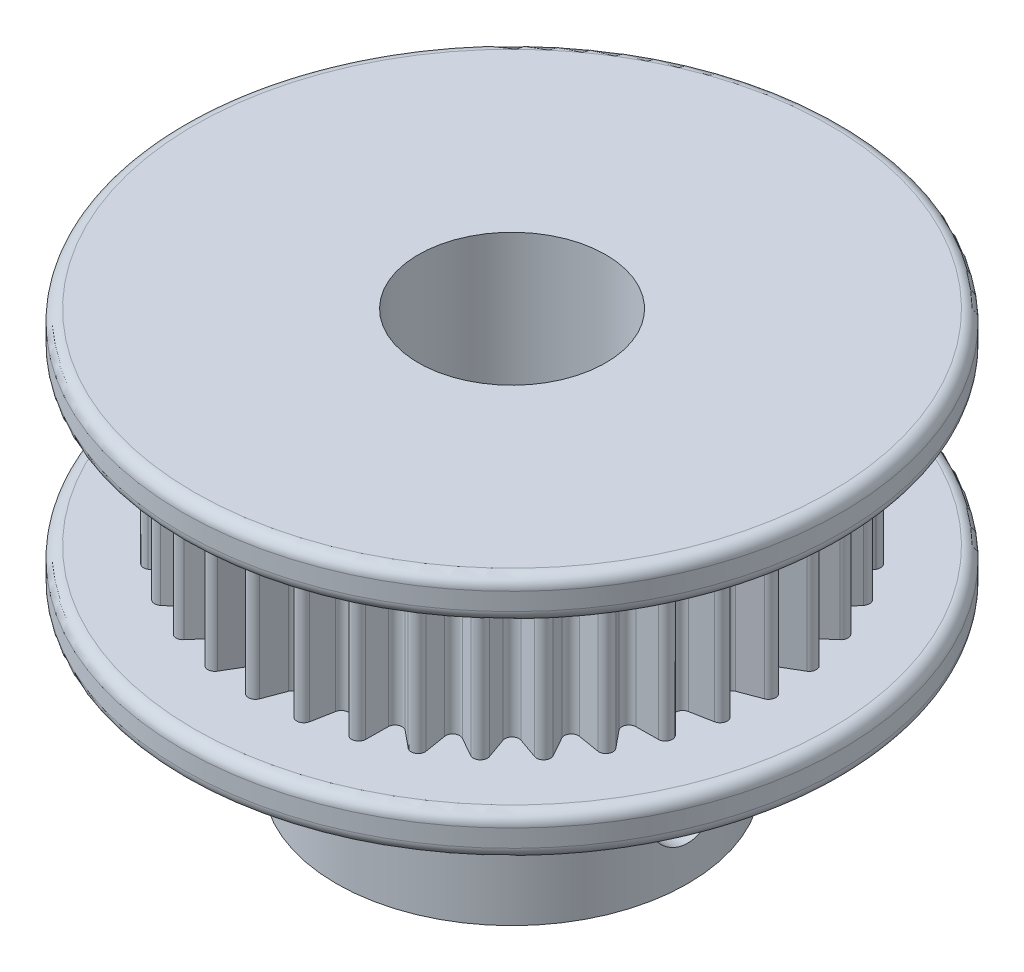
from build123d import *

# Parameters (mm, degrees)
SKETCH1_R           = 7.5
BOSS_EXTRUDE1_DEPTH = 7
SKETCH7_R           = 14.065
BOSS_EXTRUDE5_DEPTH = 1.75
BOSS_EXTRUDE7_DEPTH = 7
SKETCH8_R           = 14.065
BOSS_EXTRUDE6_DEPTH = 1.75
SKETCH4_R           = 4
CUT_EXTRUDE4_DEPTH  = 18.5
SKETCH5_R           = 1.5
CUT_EXTRUDE2_DEPTH  = 15.065
SKETCH6_R           = 1.5
CUT_EXTRUDE3_DEPTH  = 15.065
FILLET1_R           = 0.5


with BuildPart() as part:
    # Sketch1 → Boss-Extrude1 (new body)
    with BuildSketch(Plane(origin=(0, 0, 0), x_dir=(1, 0, 0), z_dir=(0, 1, 0))):
        Circle(SKETCH1_R)
    extrude(amount=BOSS_EXTRUDE1_DEPTH)

    # Sketch7 → Boss-Extrude5 (add)
    with BuildSketch(Plane(origin=(0, 7, 0), x_dir=(1, 0, 0), z_dir=(0, 1, 0))):
        Circle(SKETCH7_R)
    extrude(amount=BOSS_EXTRUDE5_DEPTH)

    # Sketch9 → Boss-Extrude7 (add)
    with BuildSketch(Plane(origin=(0, 8.75, 0), x_dir=(1, 0, 0), z_dir=(0, 1, 0))):
        with BuildLine():
            Line((0.280660726, 11.055969605), (0.617769602, 10.163136024))
            ThreePointArc((0.617769602, 10.163136024), (0.872283604, 9.970247219), (1.156425757, 10.116009717))
            Line((1.156425757, 10.116009717), (1.643452116, 10.936740807))
            ThreePointArc((1.643452116, 10.936740807), (1.776289931, 11.056290401), (1.953541999, 11.079087221))
            ThreePointArc((1.953541999, 11.079087221), (2.112307487, 10.99704144), (2.196245833, 10.83926836))
            Line((2.196245833, 10.83926836), (2.373194343, 9.901460586))
            ThreePointArc((2.373194343, 9.901460586), (2.590346917, 9.667306303), (2.895483704, 9.761513574))
            Line((2.895483704, 9.761513574), (3.517629496, 10.485204675))
            ThreePointArc((3.517629496, 10.485204675), (3.669208776, 10.579870997), (3.847726612, 10.571541984))
            ThreePointArc((3.847726612, 10.571541984), (3.989832996, 10.463173324), (4.045099122, 10.293221432))
            Line((4.045099122, 10.293221432), (4.056510776, 9.338934278))
            ThreePointArc((4.056510776, 9.338934278), (4.229703849, 9.070629176), (4.546563843, 9.11041878))
            Line((4.546563843, 9.11041878), (5.284925484, 9.715080904))
            ThreePointArc((5.284925484, 9.715080904), (5.450640568, 9.781987566), (5.625, 9.742785793))
            ThreePointArc((5.625, 9.742785793), (5.746129448, 9.611386982), (5.771044121, 9.434420178))
            Line((5.771044121, 9.434420178), (5.616572181, 8.492649178))
            ThreePointArc((5.616572181, 8.492649178), (5.74054337, 8.198345572), (6.059498941, 8.182508521))
            Line((6.059498941, 8.182508521), (6.891641686, 8.649769316))
            ThreePointArc((6.891641686, 8.649769316), (7.066457405, 8.686883393), (7.231360609, 8.617999985))
            ThreePointArc((7.231360609, 8.617999985), (7.327832664, 8.46756351), (7.321638864, 8.288958842))
            Line((7.321638864, 8.288958842), (7.005976882, 7.38831923))
            ThreePointArc((7.005976882, 7.38831923), (7.076959386, 7.076959386), (7.38831923, 7.005976882))
            Line((7.38831923, 7.005976882), (8.288958842, 7.321638864))
            ThreePointArc((8.288958842, 7.321638864), (8.46756351, 7.327832664), (8.617999985, 7.231360609))
            ThreePointArc((8.617999985, 7.231360609), (8.686883393, 7.066457405), (8.649769316, 6.891641686))
            Line((8.649769316, 6.891641686), (8.182508521, 6.059498941))
            ThreePointArc((8.182508521, 6.059498941), (8.198345572, 5.74054337), (8.492649178, 5.616572181))
            Line((8.492649178, 5.616572181), (9.434420178, 5.771044121))
            ThreePointArc((9.434420178, 5.771044121), (9.611386982, 5.746129448), (9.742785793, 5.625))
            ThreePointArc((9.742785793, 5.625), (9.781987566, 5.450640568), (9.715080904, 5.284925484))
            Line((9.715080904, 5.284925484), (9.11041878, 4.546563843))
            ThreePointArc((9.11041878, 4.546563843), (9.070629176, 4.229703849), (9.338934278, 4.056510776))
            Line((9.338934278, 4.056510776), (10.293221432, 4.045099122))
            ThreePointArc((10.293221432, 4.045099122), (10.463173324, 3.989832996), (10.571541984, 3.847726612))
            ThreePointArc((10.571541984, 3.847726612), (10.579870997, 3.669208776), (10.485204675, 3.517629496))
            Line((10.485204675, 3.517629496), (9.761513574, 2.895483704))
            ThreePointArc((9.761513574, 2.895483704), (9.667306303, 2.590346917), (9.901460586, 2.373194343))
            Line((9.901460586, 2.373194343), (10.83926836, 2.196245833))
            ThreePointArc((10.83926836, 2.196245833), (10.99704144, 2.112307487), (11.079087221, 1.953541999))
            ThreePointArc((11.079087221, 1.953541999), (11.056290401, 1.776289931), (10.936740807, 1.643452116))
            Line((10.936740807, 1.643452116), (10.116009717, 1.156425757))
            ThreePointArc((10.116009717, 1.156425757), (9.970247219, 0.872283604), (10.163136024, 0.617769602))
            Line((10.163136024, 0.617769602), (11.055969605, 0.280660726))
            ThreePointArc((11.055969605, 0.280660726), (11.196770016, 0.170600584), (11.25, 0))
            ThreePointArc((11.25, 0), (11.196770016, -0.170600584), (11.055969605, -0.280660726))
            Line((11.055969605, -0.280660726), (10.163136024, -0.617769602))
            ThreePointArc((10.163136024, -0.617769602), (9.970247219, -0.872283604), (10.116009717, -1.156425757))
            Line((10.116009717, -1.156425757), (10.936740807, -1.643452116))
            ThreePointArc((10.936740807, -1.643452116), (11.056290401, -1.776289931), (11.079087221, -1.953541999))
            ThreePointArc((11.079087221, -1.953541999), (10.99704144, -2.112307487), (10.83926836, -2.196245833))
            Line((10.83926836, -2.196245833), (9.901460586, -2.373194343))
            ThreePointArc((9.901460586, -2.373194343), (9.667306303, -2.590346917), (9.761513574, -2.895483704))
            Line((9.761513574, -2.895483704), (10.485204675, -3.517629496))
            ThreePointArc((10.485204675, -3.517629496), (10.579870997, -3.669208776), (10.571541984, -3.847726612))
            ThreePointArc((10.571541984, -3.847726612), (10.463173324, -3.989832996), (10.293221432, -4.045099122))
            Line((10.293221432, -4.045099122), (9.338934278, -4.056510776))
            ThreePointArc((9.338934278, -4.056510776), (9.070629176, -4.229703849), (9.11041878, -4.546563843))
            Line((9.11041878, -4.546563843), (9.715080904, -5.284925484))
            ThreePointArc((9.715080904, -5.284925484), (9.781987566, -5.450640568), (9.742785793, -5.625))
            ThreePointArc((9.742785793, -5.625), (9.611386982, -5.746129448), (9.434420178, -5.771044121))
            Line((9.434420178, -5.771044121), (8.492649178, -5.616572181))
            ThreePointArc((8.492649178, -5.616572181), (8.198345572, -5.74054337), (8.182508521, -6.059498941))
            Line((8.182508521, -6.059498941), (8.649769316, -6.891641686))
            ThreePointArc((8.649769316, -6.891641686), (8.686883393, -7.066457405), (8.617999985, -7.231360609))
            ThreePointArc((8.617999985, -7.231360609), (8.46756351, -7.327832664), (8.288958842, -7.321638864))
            Line((8.288958842, -7.321638864), (7.38831923, -7.005976882))
            ThreePointArc((7.38831923, -7.005976882), (7.076959386, -7.076959386), (7.005976882, -7.38831923))
            Line((7.005976882, -7.38831923), (7.321638864, -8.288958842))
            ThreePointArc((7.321638864, -8.288958842), (7.327832664, -8.46756351), (7.231360609, -8.617999985))
            ThreePointArc((7.231360609, -8.617999985), (7.066457405, -8.686883393), (6.891641686, -8.649769316))
            Line((6.891641686, -8.649769316), (6.059498941, -8.182508521))
            ThreePointArc((6.059498941, -8.182508521), (5.74054337, -8.198345572), (5.616572181, -8.492649178))
            Line((5.616572181, -8.492649178), (5.771044121, -9.434420178))
            ThreePointArc((5.771044121, -9.434420178), (5.746129448, -9.611386982), (5.625, -9.742785793))
            ThreePointArc((5.625, -9.742785793), (5.450640568, -9.781987566), (5.284925484, -9.715080904))
            Line((5.284925484, -9.715080904), (4.546563843, -9.11041878))
            ThreePointArc((4.546563843, -9.11041878), (4.229703849, -9.070629176), (4.056510776, -9.338934278))
            Line((4.056510776, -9.338934278), (4.045099122, -10.293221432))
            ThreePointArc((4.045099122, -10.293221432), (3.989832996, -10.463173324), (3.847726612, -10.571541984))
            ThreePointArc((3.847726612, -10.571541984), (3.669208776, -10.579870997), (3.517629496, -10.485204675))
            Line((3.517629496, -10.485204675), (2.895483704, -9.761513574))
            ThreePointArc((2.895483704, -9.761513574), (2.590346917, -9.667306303), (2.373194343, -9.901460586))
            Line((2.373194343, -9.901460586), (2.196245833, -10.83926836))
            ThreePointArc((2.196245833, -10.83926836), (2.112307487, -10.99704144), (1.953541999, -11.079087221))
            ThreePointArc((1.953541999, -11.079087221), (1.776289931, -11.056290401), (1.643452116, -10.936740807))
            Line((1.643452116, -10.936740807), (1.156425757, -10.116009717))
            ThreePointArc((1.156425757, -10.116009717), (0.872283604, -9.970247219), (0.617769602, -10.163136024))
            Line((0.617769602, -10.163136024), (0.280660726, -11.055969605))
            ThreePointArc((0.280660726, -11.055969605), (0.170600584, -11.196770016), (0, -11.25))
            ThreePointArc((0, -11.25), (-0.170600584, -11.196770016), (-0.280660726, -11.055969605))
            Line((-0.280660726, -11.055969605), (-0.617769602, -10.163136024))
            ThreePointArc((-0.617769602, -10.163136024), (-0.872283604, -9.970247219), (-1.156425757, -10.116009717))
            Line((-1.156425757, -10.116009717), (-1.643452116, -10.936740807))
            ThreePointArc((-1.643452116, -10.936740807), (-1.776289931, -11.056290401), (-1.953541999, -11.079087221))
            ThreePointArc((-1.953541999, -11.079087221), (-2.112307487, -10.99704144), (-2.196245833, -10.83926836))
            Line((-2.196245833, -10.83926836), (-2.373194343, -9.901460586))
            ThreePointArc((-2.373194343, -9.901460586), (-2.590346917, -9.667306303), (-2.895483704, -9.761513574))
            Line((-2.895483704, -9.761513574), (-3.517629496, -10.485204675))
            ThreePointArc((-3.517629496, -10.485204675), (-3.669208776, -10.579870997), (-3.847726612, -10.571541984))
            ThreePointArc((-3.847726612, -10.571541984), (-3.989832996, -10.463173324), (-4.045099122, -10.293221432))
            Line((-4.045099122, -10.293221432), (-4.056510776, -9.338934278))
            ThreePointArc((-4.056510776, -9.338934278), (-4.229703849, -9.070629176), (-4.546563843, -9.11041878))
            Line((-4.546563843, -9.11041878), (-5.284925484, -9.715080904))
            ThreePointArc((-5.284925484, -9.715080904), (-5.450640568, -9.781987566), (-5.625, -9.742785793))
            ThreePointArc((-5.625, -9.742785793), (-5.746129448, -9.611386982), (-5.771044121, -9.434420178))
            Line((-5.771044121, -9.434420178), (-5.616572181, -8.492649178))
            ThreePointArc((-5.616572181, -8.492649178), (-5.74054337, -8.198345572), (-6.059498941, -8.182508521))
            Line((-6.059498941, -8.182508521), (-6.891641686, -8.649769316))
            ThreePointArc((-6.891641686, -8.649769316), (-7.066457405, -8.686883393), (-7.231360609, -8.617999985))
            ThreePointArc((-7.231360609, -8.617999985), (-7.327832664, -8.46756351), (-7.321638864, -8.288958842))
            Line((-7.321638864, -8.288958842), (-7.005976882, -7.38831923))
            ThreePointArc((-7.005976882, -7.38831923), (-7.076959386, -7.076959386), (-7.38831923, -7.005976882))
            Line((-7.38831923, -7.005976882), (-8.288958842, -7.321638864))
            ThreePointArc((-8.288958842, -7.321638864), (-8.46756351, -7.327832664), (-8.617999985, -7.231360609))
            ThreePointArc((-8.617999985, -7.231360609), (-8.686883393, -7.066457405), (-8.649769316, -6.891641686))
            Line((-8.649769316, -6.891641686), (-8.182508521, -6.059498941))
            ThreePointArc((-8.182508521, -6.059498941), (-8.198345572, -5.74054337), (-8.492649178, -5.616572181))
            Line((-8.492649178, -5.616572181), (-9.434420178, -5.771044121))
            ThreePointArc((-9.434420178, -5.771044121), (-9.611386982, -5.746129448), (-9.742785793, -5.625))
            ThreePointArc((-9.742785793, -5.625), (-9.781987566, -5.450640568), (-9.715080904, -5.284925484))
            Line((-9.715080904, -5.284925484), (-9.11041878, -4.546563843))
            ThreePointArc((-9.11041878, -4.546563843), (-9.070629176, -4.229703849), (-9.338934278, -4.056510776))
            Line((-9.338934278, -4.056510776), (-10.293221432, -4.045099122))
            ThreePointArc((-10.293221432, -4.045099122), (-10.463173324, -3.989832996), (-10.571541984, -3.847726612))
            ThreePointArc((-10.571541984, -3.847726612), (-10.579870997, -3.669208776), (-10.485204675, -3.517629496))
            Line((-10.485204675, -3.517629496), (-9.761513574, -2.895483704))
            ThreePointArc((-9.761513574, -2.895483704), (-9.667306303, -2.590346917), (-9.901460586, -2.373194343))
            Line((-9.901460586, -2.373194343), (-10.83926836, -2.196245833))
            ThreePointArc((-10.83926836, -2.196245833), (-10.99704144, -2.112307487), (-11.079087221, -1.953541999))
            ThreePointArc((-11.079087221, -1.953541999), (-11.056290401, -1.776289931), (-10.936740807, -1.643452116))
            Line((-10.936740807, -1.643452116), (-10.116009717, -1.156425757))
            ThreePointArc((-10.116009717, -1.156425757), (-9.970247219, -0.872283604), (-10.163136024, -0.617769602))
            Line((-10.163136024, -0.617769602), (-11.055969605, -0.280660726))
            ThreePointArc((-11.055969605, -0.280660726), (-11.196770016, -0.170600584), (-11.25, 0))
            ThreePointArc((-11.25, 0), (-11.196770016, 0.170600584), (-11.055969605, 0.280660726))
            Line((-11.055969605, 0.280660726), (-10.163136024, 0.617769602))
            ThreePointArc((-10.163136024, 0.617769602), (-9.970247219, 0.872283604), (-10.116009717, 1.156425757))
            Line((-10.116009717, 1.156425757), (-10.936740807, 1.643452116))
            ThreePointArc((-10.936740807, 1.643452116), (-11.056290401, 1.776289931), (-11.079087221, 1.953541999))
            ThreePointArc((-11.079087221, 1.953541999), (-10.99704144, 2.112307487), (-10.83926836, 2.196245833))
            Line((-10.83926836, 2.196245833), (-9.901460586, 2.373194343))
            ThreePointArc((-9.901460586, 2.373194343), (-9.667306303, 2.590346917), (-9.761513574, 2.895483704))
            Line((-9.761513574, 2.895483704), (-10.485204675, 3.517629496))
            ThreePointArc((-10.485204675, 3.517629496), (-10.579870997, 3.669208776), (-10.571541984, 3.847726612))
            ThreePointArc((-10.571541984, 3.847726612), (-10.463173324, 3.989832996), (-10.293221432, 4.045099122))
            Line((-10.293221432, 4.045099122), (-9.338934278, 4.056510776))
            ThreePointArc((-9.338934278, 4.056510776), (-9.070629176, 4.229703849), (-9.11041878, 4.546563843))
            Line((-9.11041878, 4.546563843), (-9.715080904, 5.284925484))
            ThreePointArc((-9.715080904, 5.284925484), (-9.781987566, 5.450640568), (-9.742785793, 5.625))
            ThreePointArc((-9.742785793, 5.625), (-9.611386982, 5.746129448), (-9.434420178, 5.771044121))
            Line((-9.434420178, 5.771044121), (-8.492649178, 5.616572181))
            ThreePointArc((-8.492649178, 5.616572181), (-8.198345572, 5.74054337), (-8.182508521, 6.059498941))
            Line((-8.182508521, 6.059498941), (-8.649769316, 6.891641686))
            ThreePointArc((-8.649769316, 6.891641686), (-8.686883393, 7.066457405), (-8.617999985, 7.231360609))
            ThreePointArc((-8.617999985, 7.231360609), (-8.46756351, 7.327832664), (-8.288958842, 7.321638864))
            Line((-8.288958842, 7.321638864), (-7.38831923, 7.005976882))
            ThreePointArc((-7.38831923, 7.005976882), (-7.076959386, 7.076959386), (-7.005976882, 7.38831923))
            Line((-7.005976882, 7.38831923), (-7.321638864, 8.288958842))
            ThreePointArc((-7.321638864, 8.288958842), (-7.327832664, 8.46756351), (-7.231360609, 8.617999985))
            ThreePointArc((-7.231360609, 8.617999985), (-7.066457405, 8.686883393), (-6.891641686, 8.649769316))
            Line((-6.891641686, 8.649769316), (-6.059498941, 8.182508521))
            ThreePointArc((-6.059498941, 8.182508521), (-5.74054337, 8.198345572), (-5.616572181, 8.492649178))
            Line((-5.616572181, 8.492649178), (-5.771044121, 9.434420178))
            ThreePointArc((-5.771044121, 9.434420178), (-5.746129448, 9.611386982), (-5.625, 9.742785793))
            ThreePointArc((-5.625, 9.742785793), (-5.450640568, 9.781987566), (-5.284925484, 9.715080904))
            Line((-5.284925484, 9.715080904), (-4.546563843, 9.11041878))
            ThreePointArc((-4.546563843, 9.11041878), (-4.229703849, 9.070629176), (-4.056510776, 9.338934278))
            Line((-4.056510776, 9.338934278), (-4.045099122, 10.293221432))
            ThreePointArc((-4.045099122, 10.293221432), (-3.989832996, 10.463173324), (-3.847726612, 10.571541984))
            ThreePointArc((-3.847726612, 10.571541984), (-3.669208776, 10.579870997), (-3.517629496, 10.485204675))
            Line((-3.517629496, 10.485204675), (-2.895483704, 9.761513574))
            ThreePointArc((-2.895483704, 9.761513574), (-2.590346917, 9.667306303), (-2.373194343, 9.901460586))
            Line((-2.373194343, 9.901460586), (-2.196245833, 10.83926836))
            ThreePointArc((-2.196245833, 10.83926836), (-2.112307487, 10.99704144), (-1.953541999, 11.079087221))
            ThreePointArc((-1.953541999, 11.079087221), (-1.776289931, 11.056290401), (-1.643452116, 10.936740807))
            Line((-1.643452116, 10.936740807), (-1.156425757, 10.116009717))
            ThreePointArc((-1.156425757, 10.116009717), (-0.872283604, 9.970247219), (-0.617769602, 10.163136024))
            Line((-0.617769602, 10.163136024), (-0.280660726, 11.055969605))
            ThreePointArc((-0.280660726, 11.055969605), (-0.170600584, 11.196770016), (0, 11.25))
            ThreePointArc((0, 11.25), (0.170600584, 11.196770016), (0.280660726, 11.055969605))
        make_face()
    extrude(amount=BOSS_EXTRUDE7_DEPTH)

    # Sketch8 → Boss-Extrude6 (add)
    with BuildSketch(Plane(origin=(0, 15.75, 0), x_dir=(1, 0, 0), z_dir=(0, 1, 0))):
        Circle(SKETCH8_R)
    extrude(amount=BOSS_EXTRUDE6_DEPTH)

    # Sketch4 → Cut-Extrude4 (cut, through all)
    with BuildSketch(Plane.XZ):
        Circle(SKETCH4_R)
    extrude(amount=-CUT_EXTRUDE4_DEPTH, mode=Mode.SUBTRACT)

    # Sketch5 → Cut-Extrude2 (cut, through all)
    with BuildSketch(Plane(origin=(0, 0, 0), x_dir=(0, 0, -1), z_dir=(1, 0, 0))):
        with Locations((0, 3)):
            Circle(SKETCH5_R)
    extrude(amount=CUT_EXTRUDE2_DEPTH, mode=Mode.SUBTRACT)

    # Sketch6 → Cut-Extrude3 (cut, through all)
    with BuildSketch(Plane.XY):
        with Locations((0, 3)):
            Circle(SKETCH6_R)
    extrude(amount=-CUT_EXTRUDE3_DEPTH, mode=Mode.SUBTRACT)

    # Fillet1
    fillet1_edges = [part.edges().sort_by_distance(p)[0] for p in [
        (-14.065, 15.75, 0),
        (-14.065, 17.5, 0),
        (-14.065, 7, 0),
        (-14.065, 8.75, 0),
    ]]
    fillet(fillet1_edges, radius=FILLET1_R)


solid = part.part
